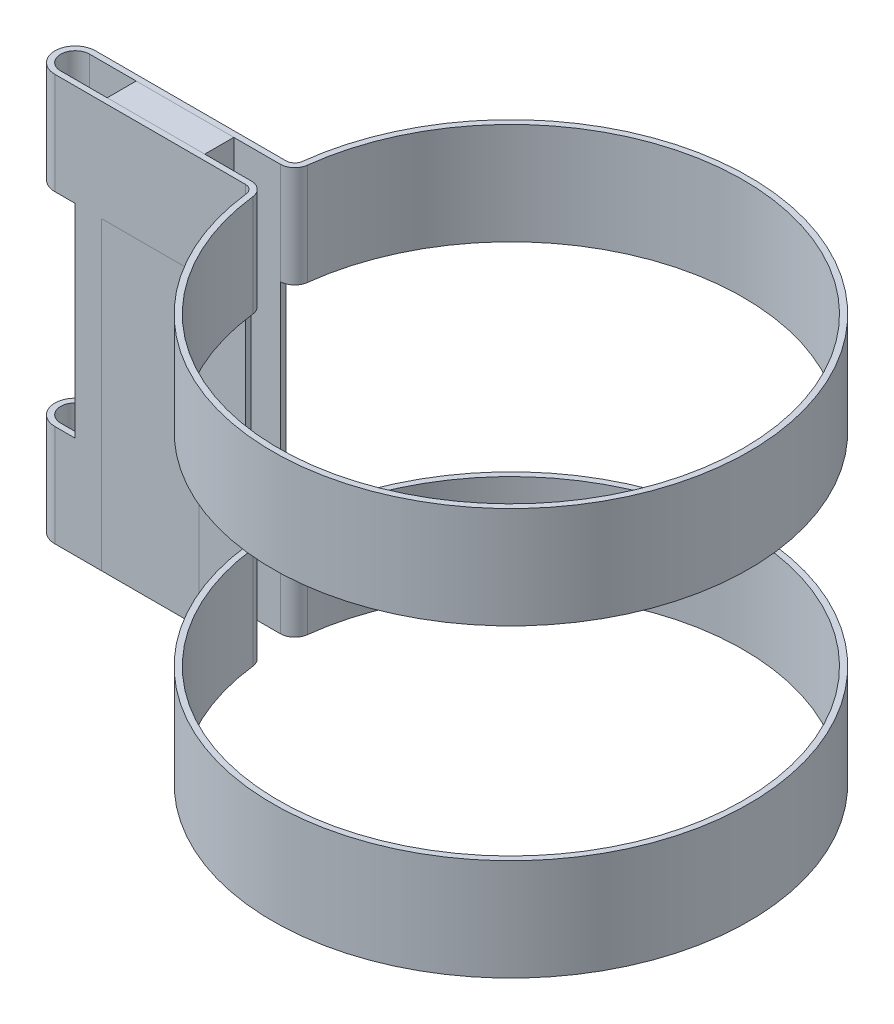
from build123d import *

# Parameters (mm, degrees)
BOSS_EXTRUDE1_DEPTH     = 70
SKETCH2_W               = 7
SKETCH2_H               = 35
CUT_EXTRUDE1_DEPTH      = 7
SKETCH3_W               = 84.40971508
SKETCH3_H               = 35
CUT_EXTRUDE2_DEPTH      = 38.5
CUT_EXTRUDE2_DEPTH_BACK = 45.5
SKETCH4_W               = 16.79514246
SKETCH4_H               = 7
BOSS_EXTRUDE2_DEPTH     = 70


with BuildPart() as part:
    # Sketch1 → Boss-Extrude1 (new body)
    with BuildSketch(Plane(origin=(0, 0, 0), x_dir=(1, 0, 0), z_dir=(0, 1, 0))):
        with BuildLine():
            Line((-75, 3.5), (-42.20485754, 3.5))
            ThreePointArc((-42.20485754, 3.5), (-41.208540794, 3.878682498), (-40.715274333, 4.823529412))
            ThreePointArc((-40.715274333, 4.823529412), (41, 0), (-40.715274333, -4.823529412))
            ThreePointArc((-40.715274333, -4.823529412), (-41.208540794, -3.878682498), (-42.20485754, -3.5))
            Line((-42.20485754, -3.5), (-75, -3.5))
            ThreePointArc((-75, -3.5), (-78.5, 0), (-75, 3.5))
        make_face()
        with BuildLine():
            Line((-75, 2.5), (-42.20485754, 2.5))
            ThreePointArc((-42.20485754, 2.5), (-40.54432963, 3.131137496), (-39.722218861, 4.705882353))
            ThreePointArc((-39.722218861, 4.705882353), (40, 0), (-39.722218861, -4.705882353))
            ThreePointArc((-39.722218861, -4.705882353), (-40.54432963, -3.131137496), (-42.20485754, -2.5))
            Line((-42.20485754, -2.5), (-75, -2.5))
            ThreePointArc((-75, -2.5), (-77.5, 0), (-75, 2.5))
        make_face(mode=Mode.SUBTRACT)
    extrude(amount=BOSS_EXTRUDE1_DEPTH)

    # Sketch2 → Cut-Extrude1 (cut)
    with BuildSketch(Plane.XY.offset(3.5)):
        with Locations((-75, 35)):
            Rectangle(SKETCH2_W, SKETCH2_H)
    extrude(amount=-CUT_EXTRUDE1_DEPTH, mode=Mode.SUBTRACT)

    # Sketch3 → Cut-Extrude2 (cut, two sides)
    with BuildSketch(Plane.XY.offset(3.5)) as cut_extrude2_sk:
        with Locations((0, 35)):
            Rectangle(SKETCH3_W, SKETCH3_H)
    extrude(amount=CUT_EXTRUDE2_DEPTH, mode=Mode.SUBTRACT)
    extrude(cut_extrude2_sk.sketch, amount=-CUT_EXTRUDE2_DEPTH_BACK, mode=Mode.SUBTRACT)


with BuildPart() as body_2:
    # Sketch4 → Boss-Extrude2 (new body)
    with BuildSketch(Plane(origin=(0, 70, 0), x_dir=(1, 0, 0), z_dir=(0, 1, 0))):
        with Locations((-58.60242877, 0)):
            Rectangle(SKETCH4_W, SKETCH4_H)
    extrude(amount=-BOSS_EXTRUDE2_DEPTH)


solid = Compound([part.part, body_2.part])
